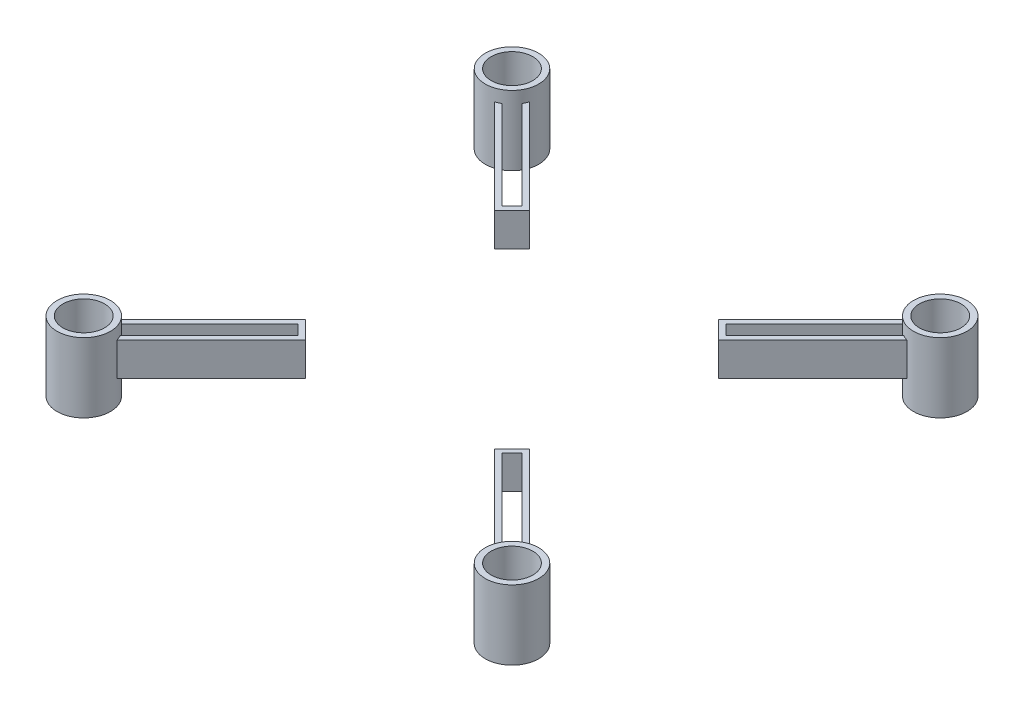
from build123d import *

# Parameters (mm, degrees)
SKETCH1_R             = 3.799855969
SKETCH1_R_2           = 2.96
BOSS_EXTRUDE1_DEPTH   = 9.89
BOSS_EXTRUDE1_2_DEPTH = 9.89
BOSS_EXTRUDE1_3_DEPTH = 9.89
BOSS_EXTRUDE1_4_DEPTH = 9.89
BOSS_EXTRUDE2_DEPTH   = 4.74


with BuildPart() as part:
    # Sketch1 → Boss-Extrude1 (new body)
    with BuildSketch(Plane(origin=(0, 0, 0), x_dir=(1, 0, 0), z_dir=(0, 1, 0))):
        with Locations((-30.445, -30.445)):
            Circle(SKETCH1_R)
        with Locations((-30.445, -30.445)):
            Circle(SKETCH1_R_2, mode=Mode.SUBTRACT)
    extrude(amount=BOSS_EXTRUDE1_DEPTH)


with BuildPart() as body_2:
    # Sketch1 → Boss-Extrude1 2 (new body)
    with BuildSketch(Plane(origin=(0, 0, 0), x_dir=(1, 0, 0), z_dir=(0, 1, 0))):
        with Locations((-30.445, 30.445)):
            Circle(SKETCH1_R)
        with Locations((-30.445, 30.445)):
            Circle(SKETCH1_R_2, mode=Mode.SUBTRACT)
    extrude(amount=BOSS_EXTRUDE1_2_DEPTH)

    # Sketch2 → Boss-Extrude2 (add)
    with BuildSketch(Plane(origin=(0, 8.180000118, 0), x_dir=(1, 0, 0), z_dir=(0, 1, 0))):
        with BuildLine():
            Line((-26.815816595, 29.318974601), (-13.426848066, 15.930006071))
            Line((-13.426848066, 15.930006071), (-15.930006071, 13.426848066))
            Line((-15.930006071, 13.426848066), (-29.318974601, 26.815816595))
            ThreePointArc((-29.318974601, 26.815816595), (-28.939956198, 26.95591007), (-28.577957455, 27.135459621))
            Line((-28.577957455, 27.135459621), (-15.930006071, 14.487508237))
            Line((-15.930006071, 14.487508237), (-14.487508237, 15.930006071))
            Line((-14.487508237, 15.930006071), (-27.135459621, 28.577957455))
            ThreePointArc((-27.135459621, 28.577957455), (-26.95591007, 28.939956198), (-26.815816595, 29.318974601))
        make_face()
        with BuildLine():
            Line((29.318974601, 26.815816595), (15.930006071, 13.426848066))
            Line((15.930006071, 13.426848066), (13.426848066, 15.930006071))
            Line((13.426848066, 15.930006071), (26.815816595, 29.318974601))
            ThreePointArc((26.815816595, 29.318974601), (26.95591007, 28.939956198), (27.135459621, 28.577957455))
            Line((27.135459621, 28.577957455), (14.487508237, 15.930006071))
            Line((14.487508237, 15.930006071), (15.930006071, 14.487508237))
            Line((15.930006071, 14.487508237), (28.577957455, 27.135459621))
            ThreePointArc((28.577957455, 27.135459621), (28.939956198, 26.95591007), (29.318974601, 26.815816595))
        make_face()
        with BuildLine():
            Line((26.815816595, -29.318974601), (13.426848066, -15.930006071))
            Line((13.426848066, -15.930006071), (15.930006071, -13.426848066))
            Line((15.930006071, -13.426848066), (29.318974601, -26.815816595))
            ThreePointArc((29.318974601, -26.815816595), (28.939956198, -26.95591007), (28.577957455, -27.135459621))
            Line((28.577957455, -27.135459621), (15.930006071, -14.487508237))
            Line((15.930006071, -14.487508237), (14.487508237, -15.930006071))
            Line((14.487508237, -15.930006071), (27.135459621, -28.577957455))
            ThreePointArc((27.135459621, -28.577957455), (26.95591007, -28.939956198), (26.815816595, -29.318974601))
        make_face()
        with BuildLine():
            Line((-29.318974601, -26.815816595), (-15.930006071, -13.426848066))
            Line((-15.930006071, -13.426848066), (-13.426848066, -15.930006071))
            Line((-13.426848066, -15.930006071), (-26.815816595, -29.318974601))
            ThreePointArc((-26.815816595, -29.318974601), (-26.95591007, -28.939956198), (-27.135459621, -28.577957455))
            Line((-27.135459621, -28.577957455), (-14.487508237, -15.930006071))
            Line((-14.487508237, -15.930006071), (-15.930006071, -14.487508237))
            Line((-15.930006071, -14.487508237), (-28.577957455, -27.135459621))
            ThreePointArc((-28.577957455, -27.135459621), (-28.939956198, -26.95591007), (-29.318974601, -26.815816595))
        make_face()
    extrude(amount=-BOSS_EXTRUDE2_DEPTH)


with BuildPart() as body_3:
    # Sketch1 → Boss-Extrude1 3 (new body)
    with BuildSketch(Plane(origin=(0, 0, 0), x_dir=(1, 0, 0), z_dir=(0, 1, 0))):
        with Locations((30.445, 30.445)):
            Circle(SKETCH1_R)
        with Locations((30.445, 30.445)):
            Circle(SKETCH1_R_2, mode=Mode.SUBTRACT)
    extrude(amount=BOSS_EXTRUDE1_3_DEPTH)


with BuildPart() as body_4:
    # Sketch1 → Boss-Extrude1 4 (new body)
    with BuildSketch(Plane(origin=(0, 0, 0), x_dir=(1, 0, 0), z_dir=(0, 1, 0))):
        with Locations((30.445, -30.445)):
            Circle(SKETCH1_R)
        with Locations((30.445, -30.445)):
            Circle(SKETCH1_R_2, mode=Mode.SUBTRACT)
    extrude(amount=BOSS_EXTRUDE1_4_DEPTH)


solid = Compound([part.part, body_2.part, body_3.part, body_4.part])
